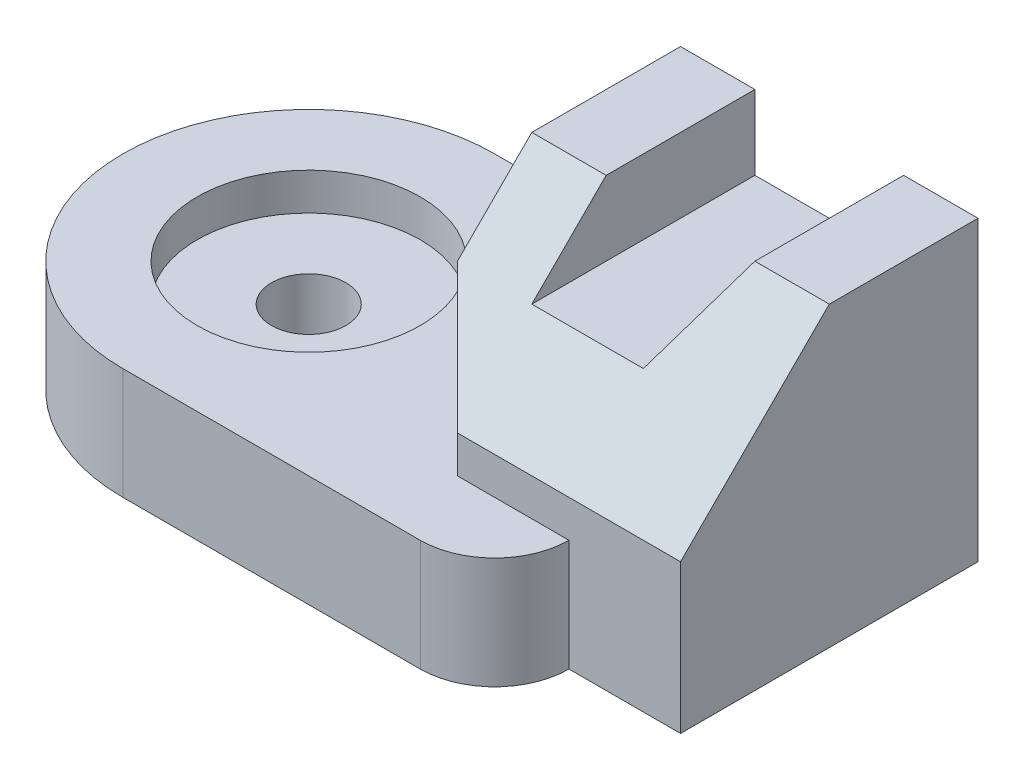
from build123d import *

# Parameters (mm, degrees)
SKETCH1_R           = 1
BOSS_EXTRUDE1_DEPTH = 3
SKETCH2_R           = 3
CUT_EXTRUDE1_DEPTH  = 1
BOSS_EXTRUDE2_DEPTH = 5
CUT_EXTRUDE2_DEPTH  = 13
CUT_EXTRUDE3_DEPTH  = 13


with BuildPart() as part:
    # Sketch1 → Boss-Extrude1 (new body)
    with BuildSketch(Plane(origin=(0, 0, 0), x_dir=(1, 0, 0), z_dir=(0, 1, 0))):
        with BuildLine():
            Line((0, 5), (13, 5))
            Line((13, 5), (13, -3))
            Line((13, -3), (10, -3))
            ThreePointArc((10, -3), (9.414213562, -4.414213562), (8, -5))
            Line((8, -5), (0, -5))
            ThreePointArc((0, -5), (-5, 0), (0, 5))
        make_face()
        Circle(SKETCH1_R, mode=Mode.SUBTRACT)
    extrude(amount=BOSS_EXTRUDE1_DEPTH)

    # Sketch2 → Cut-Extrude1 (cut)
    with BuildSketch(Plane(origin=(0, 3, 0), x_dir=(1, 0, 0), z_dir=(0, 1, 0))):
        Circle(SKETCH2_R)
    extrude(amount=-CUT_EXTRUDE1_DEPTH, mode=Mode.SUBTRACT)

    # Sketch3 → Boss-Extrude2 (add)
    with BuildSketch(Plane(origin=(0, 3, 0), x_dir=(1, 0, 0), z_dir=(0, 1, 0))):
        Polygon((13, -3), (7, -3), (5, -1), (5, 5), (13, 5), align=None)
    extrude(amount=BOSS_EXTRUDE2_DEPTH)

    # Sketch4 → Cut-Extrude2 (cut)
    with BuildSketch(Plane(origin=(13, 0, 0), x_dir=(0, 0, -1), z_dir=(1, 0, 0))):
        Polygon((-3, 4), (1, 8), (-3, 8), align=None)
    extrude(amount=-CUT_EXTRUDE2_DEPTH, mode=Mode.SUBTRACT)

    # Sketch5 → Cut-Extrude3 (cut)
    with BuildSketch(Plane(origin=(0, 0, -5), x_dir=(-1, 0, 0), z_dir=(0, 0, -1))):
        Polygon((-7, 8), (-7, 6), (-10, 6), (-11, 8), align=None)
    extrude(amount=-CUT_EXTRUDE3_DEPTH, mode=Mode.SUBTRACT)


solid = part.part
